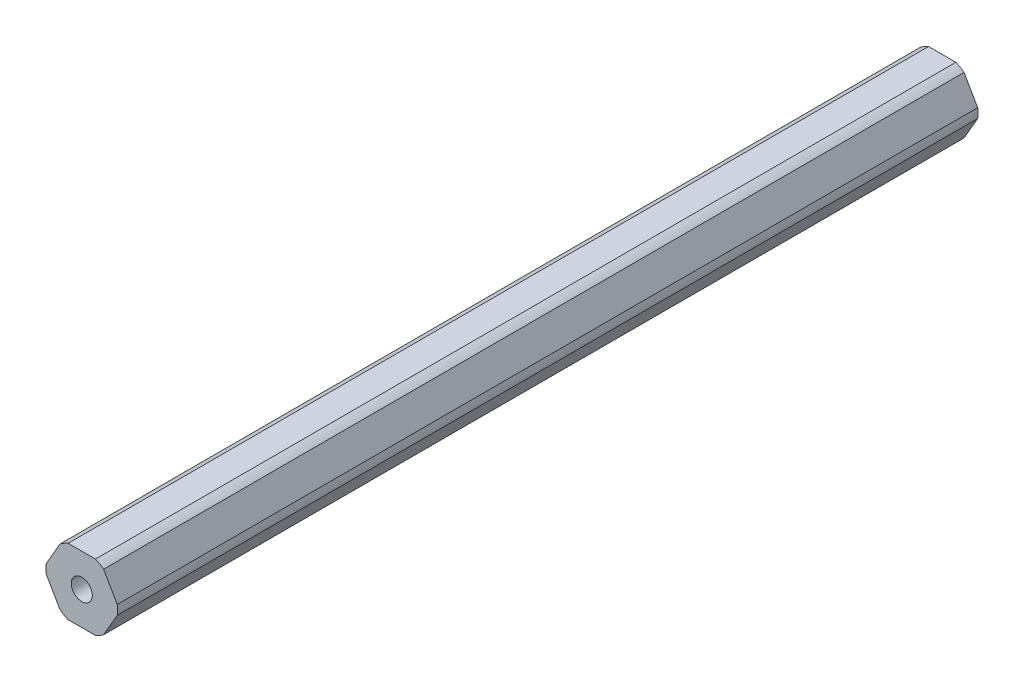
from build123d import *

# Parameters (mm, degrees)
SKETCH1_R           = 2.0193
BOSS_EXTRUDE1_DEPTH = 165.1


with BuildPart() as part:
    # Sketch1 → Boss-Extrude1 (new body)
    with BuildSketch(Plane.XY):
        with BuildLine():
            ThreePointArc((-2.623741315, 6.35), (-3.43535, 5.950200742), (-4.187390656, 5.447226632))
            Line((-4.187390656, 5.447226632), (-6.811131972, 0.902773368))
            ThreePointArc((-6.811131972, 0.902773368), (-6.8707, 0), (-6.811131972, -0.902773368))
            Line((-6.811131972, -0.902773368), (-4.187390656, -5.447226632))
            ThreePointArc((-4.187390656, -5.447226632), (-3.43535, -5.950200742), (-2.623741315, -6.35))
            Line((-2.623741315, -6.35), (2.623741315, -6.35))
            ThreePointArc((2.623741315, -6.35), (3.43535, -5.950200742), (4.187390656, -5.447226632))
            Line((4.187390656, -5.447226632), (6.811131972, -0.902773368))
            ThreePointArc((6.811131972, -0.902773368), (6.8707, 0), (6.811131972, 0.902773368))
            Line((6.811131972, 0.902773368), (4.187390656, 5.447226632))
            ThreePointArc((4.187390656, 5.447226632), (3.43535, 5.950200742), (2.623741315, 6.35))
            Line((2.623741315, 6.35), (-2.623741315, 6.35))
        make_face()
        Circle(SKETCH1_R, mode=Mode.SUBTRACT)
    extrude(amount=BOSS_EXTRUDE1_DEPTH)


solid = part.part
